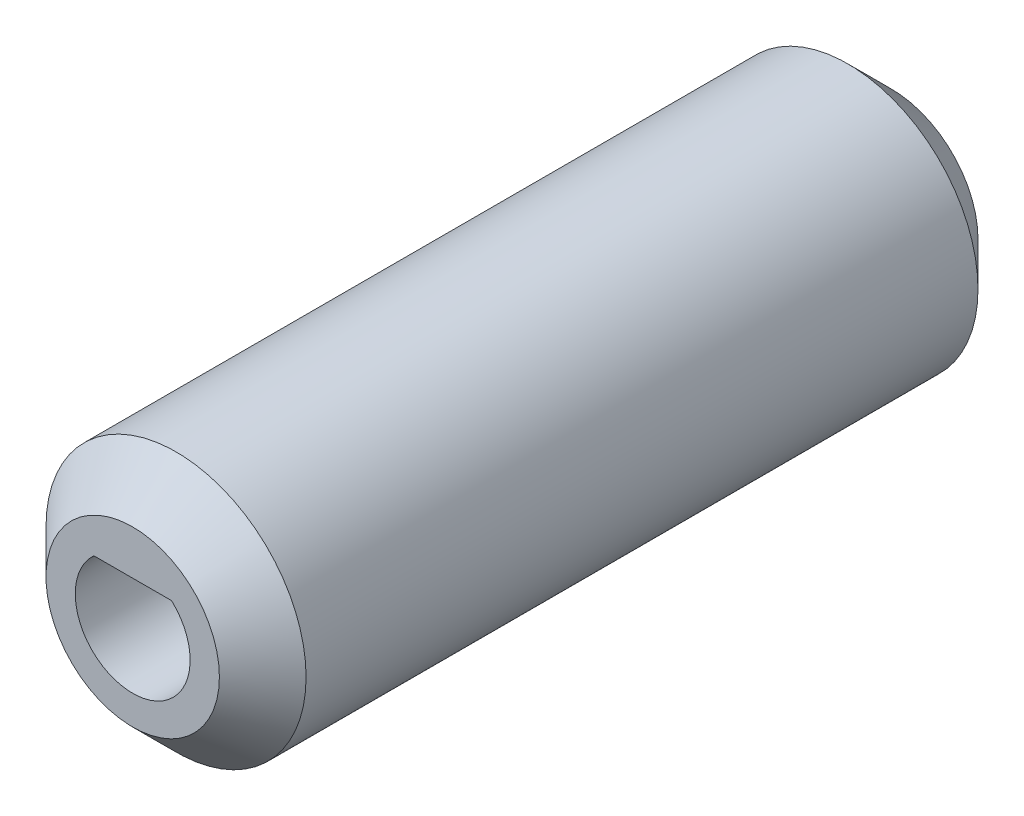
from build123d import *

# Parameters (mm, degrees)
SKETCH1_R           = 6
SKETCH1_R_2         = 2.65
BOSS_EXTRUDE1_DEPTH = 35
BOSS_EXTRUDE2_DEPTH = 35
CHAMFER1_SIZE       = 2


with BuildPart() as part:
    # Sketch1 → Boss-Extrude1 (new body)
    with BuildSketch(Plane.XY):
        Circle(SKETCH1_R)
        Circle(SKETCH1_R_2, mode=Mode.SUBTRACT)
    extrude(amount=BOSS_EXTRUDE1_DEPTH)

    # Sketch2 → Boss-Extrude2 (add)
    with BuildSketch(Plane.XY.offset(35)):
        with BuildLine():
            ThreePointArc((1.794435844, 1.95), (0, 2.65), (-1.794435844, 1.95))
            Line((-1.794435844, 1.95), (1.794435844, 1.95))
        make_face()
    extrude(amount=-BOSS_EXTRUDE2_DEPTH)

    # Chamfer1
    chamfer1_edges = [part.edges().sort_by_distance(p)[0] for p in [
        (-6, 0, 0),
        (-6, 0, 35),
    ]]
    chamfer(chamfer1_edges, length=CHAMFER1_SIZE)


solid = part.part
